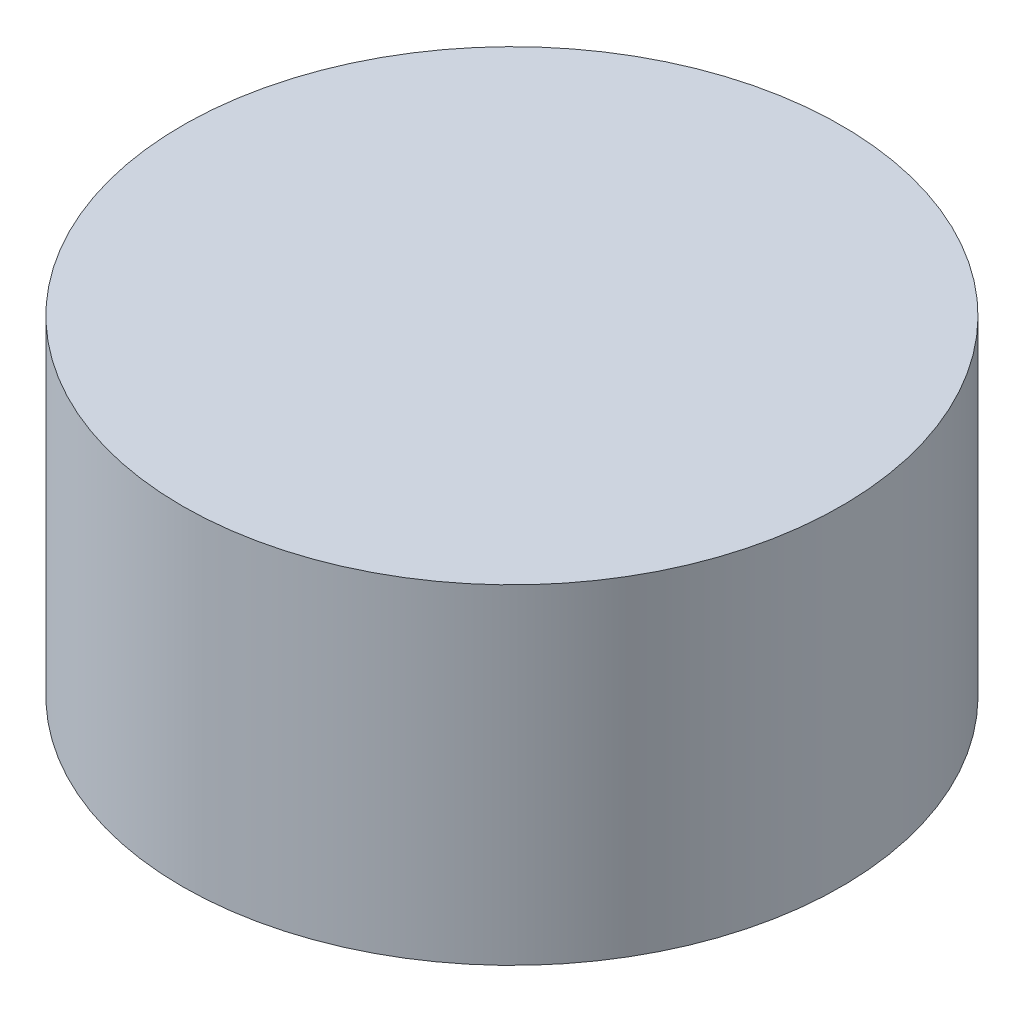
from build123d import *

# Parameters (mm, degrees)
SKETCH1_R           = 10
BOSS_EXTRUDE1_DEPTH = 10


with BuildPart() as part:
    # Sketch1 → Boss-Extrude1 (new body)
    with BuildSketch(Plane(origin=(0, 0, 0), x_dir=(1, 0, 0), z_dir=(0, 1, 0))):
        Circle(SKETCH1_R)
    extrude(amount=BOSS_EXTRUDE1_DEPTH)


solid = part.part
